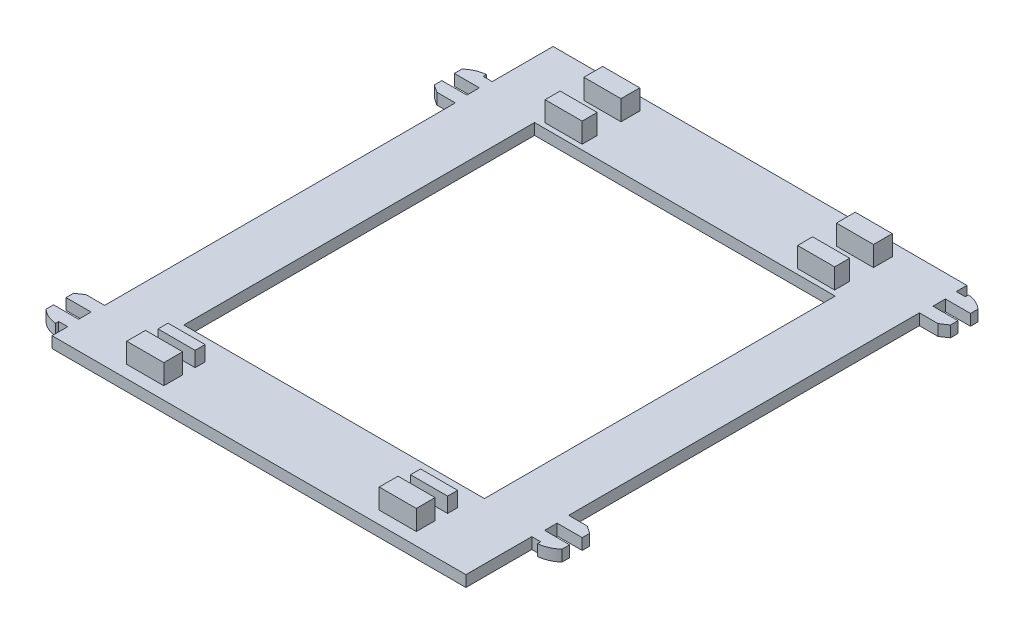
from build123d import *

# Parameters (mm, degrees)
SKETCH1_W           = 0.2
SKETCH1_H           = 2.5
SKETCH1_W_2         = 82.6
SKETCH1_H_2         = 100
BOSS_EXTRUDE1_DEPTH = 2.23
SKETCH2_W           = 7.4
SKETCH2_H           = 3.75
SKETCH2_H_2         = 3
BOSS_EXTRUDE2_DEPTH = 4
SKETCH3_W           = 60
SKETCH3_H           = 70
CUT_EXTRUDE1_DEPTH  = 10
CUT_EXTRUDE2_DEPTH  = 0.5
SKETCH5_W           = 7.4
SKETCH5_H           = 2
BOSS_EXTRUDE3_DEPTH = 3


with BuildPart() as part:
    # Sketch1 → Boss-Extrude1 (new body)
    with BuildSketch(Plane(origin=(0, 0, 0), x_dir=(1, 0, 0), z_dir=(0, 1, 0))):
        with BuildLine():
            Line((43.1, -36.85), (43.1, -37.5))
            ThreePointArc((43.1, -37.5), (44.922195524, -37.020142239), (46.5, -35.99))
            Line((46.5, -35.99), (46.5, -34.49))
            Line((46.5, -34.49), (43.1, -34.49))
            Line((43.1, -34.49), (43.1, -36.85))
        make_face()
        Polygon((41.5, -34.49), (41.3, -34.49), (41.3, -36.85), (43.1, -36.85), (43.1, -34.49), align=None)
        Polygon((45, -29.49), (41.3, -29.49), (41.3, -31.99), (41.5, -31.99), (46.5, -31.99), (46.5, -30.49), align=None)
        with Locations((41.4, -33.24)):
            Rectangle(SKETCH1_W, SKETCH1_H)
        Rectangle(SKETCH1_W_2, SKETCH1_H_2)
        Polygon((46.5, 43.01), (41.5, 43.01), (41.3, 43.01), (41.3, 40.51), (45, 40.51), (46.5, 41.51), align=None)
        with Locations((41.4, 44.26)):
            Rectangle(SKETCH1_W, SKETCH1_H)
        Polygon((41.5, 45.51), (43.1, 45.51), (43.1, 47.87), (41.3, 47.87), (41.3, 45.51), align=None)
        with BuildLine():
            ThreePointArc((43.1, 48.52), (44.922195524, 48.040142239), (46.5, 47.01))
            Line((46.5, 47.01), (46.5, 45.51))
            Line((46.5, 45.51), (43.1, 45.51))
            Line((43.1, 45.51), (43.1, 47.87))
            Line((43.1, 47.87), (43.1, 48.52))
        make_face()
        with BuildLine():
            Line((-43.1, -46.87), (-41.3, -46.87))
            Line((-41.3, -46.87), (-41.3, -44.51))
            Line((-41.3, -44.51), (-41.5, -44.51))
            Line((-41.5, -44.51), (-46.5, -44.51))
            Line((-46.5, -44.51), (-46.5, -46.01))
            ThreePointArc((-46.5, -46.01), (-44.922195524, -47.040142239), (-43.1, -47.52))
            Line((-43.1, -47.52), (-43.1, -46.87))
        make_face()
        Polygon((-41.3, -44.51), (-41.3, -39.51), (-45, -39.51), (-46.5, -40.51), (-46.5, -42.01), (-41.5, -42.01), (-41.5, -44.51), align=None)
        Polygon((-41.3, 30.49), (-41.3, 35.49), (-41.5, 35.49), (-41.5, 32.99), (-46.5, 32.99), (-46.5, 31.49), (-45, 30.49), align=None)
        with BuildLine():
            Line((-41.3, 35.49), (-41.3, 37.85))
            Line((-41.3, 37.85), (-43.1, 37.85))
            Line((-43.1, 37.85), (-43.1, 38.5))
            ThreePointArc((-43.1, 38.5), (-44.922195524, 38.020142239), (-46.5, 36.99))
            Line((-46.5, 36.99), (-46.5, 35.49))
            Line((-46.5, 35.49), (-41.5, 35.49))
            Line((-41.5, 35.49), (-41.3, 35.49))
        make_face()
    extrude(amount=BOSS_EXTRUDE1_DEPTH)

    # Sketch2 → Boss-Extrude2 (add)
    with BuildSketch(Plane(origin=(0, 2.23, 0), x_dir=(1, 0, 0), z_dir=(0, 1, 0))):
        with Locations((-25.2, -45.625)):
            Rectangle(SKETCH2_W, SKETCH2_H)
        with Locations((25.2, -45.625)):
            Rectangle(SKETCH2_W, SKETCH2_H)
        with Locations((25.2, 45.625)):
            Rectangle(SKETCH2_W, SKETCH2_H)
        with Locations((-25.2, 45.625)):
            Rectangle(SKETCH2_W, SKETCH2_H)
        with Locations((-25.2, 37.5)):
            Rectangle(SKETCH2_W, SKETCH2_H_2)
        with Locations((25.2, 37.5)):
            Rectangle(SKETCH2_W, SKETCH2_H_2)
    extrude(amount=BOSS_EXTRUDE2_DEPTH)

    # Sketch3 → Cut-Extrude1 (cut)
    with BuildSketch(Plane(origin=(0, 2.23, 0), x_dir=(1, 0, 0), z_dir=(0, 1, 0))):
        Rectangle(SKETCH3_W, SKETCH3_H)
    extrude(amount=-CUT_EXTRUDE1_DEPTH, mode=Mode.SUBTRACT)

    # Sketch4 → Cut-Extrude2 (cut)
    with BuildSketch(Plane.XZ):
        Polygon((4.640384615, -43.419230769), (4.640384615, -45.291666667), (4.070512821, -45.291666667), (4.070512821, -43.419230769), (2.198076923, -43.419230769), (2.198076923, -42.849358974), (4.070512821, -42.849358974), (4.070512821, -40.976923077), (4.640384615, -40.976923077), (4.640384615, -42.849358974), (6.512820513, -42.849358974), (6.512820513, -43.419230769), align=None)
        Polygon((1.221153846, -45.698717949), (1.221153846, -46.35), (-2.116666667, -46.35), (0.54697516, -40.651282051), (-2.03525641, -40.651282051), (-2.03525641, -40), (1.465384615, -40), (-1.198257212, -45.698717949), align=None)
        with BuildLine():
            add(Edge.make_bspline(
                [(-3.175, -44.482652244), (-3.262918211, -44.565594294), (-3.433284709, -44.726318068), (-3.671176807, -44.969181062), (-3.884395029, -45.204215059), (-4.071386431, -45.432230465), (-4.235563138, -45.650653984), (-4.373446797, -45.862117777), (-4.487450991, -46.065713922), (-4.546079998, -46.202765549), (-4.574238782, -46.268589744)],
                knots=[0, 0, 0, 0, 0.000362575, 0.000702591, 0.001019617, 0.001314251, 0.001586978, 0.001838892, 0.00207117, 0.002285828, 0.002285828, 0.002285828, 0.002285828], degree=3))
            Line((-4.574238782, -46.268589744), (-4.759955929, -46.268589744))
            add(Edge.make_bspline(
                [(-4.759955929, -46.268589744), (-4.792788221, -46.198486652), (-4.860615985, -46.053661673), (-4.986779978, -45.841364869), (-5.132525091, -45.623706079), (-5.300867212, -45.402881295), (-5.491310702, -45.177687257), (-5.702118152, -44.94759275), (-5.93585869, -44.714525691), (-6.101847246, -44.561381426), (-6.187179487, -44.482652244)],
                knots=[0, 0, 0, 0, 0.000232111, 0.000479514, 0.000739881, 0.001017698, 0.001312003, 0.001624408, 0.001953613, 0.002301902, 0.002301902, 0.002301902, 0.002301902], degree=3))
            Line((-6.187179487, -44.482652244), (-6.187179487, -44.151923077))
            add(Edge.make_bspline(
                [(-6.187179487, -44.151923077), (-6.116537815, -44.184471117), (-5.978890638, -44.247891839), (-5.781903944, -44.34935602), (-5.597143614, -44.448436612), (-5.427913951, -44.551377879), (-5.270864773, -44.651733434), (-5.129759329, -44.755968393), (-5.000056754, -44.857829341), (-4.922299946, -44.930706152), (-4.884615385, -44.966025641)],
                knots=[0, 0, 0, 0, 0.000233307, 0.000454604, 0.000664648, 0.000862076, 0.001048719, 0.001223511, 0.001388199, 0.001543075, 0.001543075, 0.001543075, 0.001543075], degree=3))
            Line((-4.884615385, -44.966025641), (-4.884615385, -38.127564103))
            Line((-4.884615385, -38.127564103), (-4.477564103, -38.127564103))
            Line((-4.477564103, -38.127564103), (-4.477564103, -44.966025641))
            add(Edge.make_bspline(
                [(-4.477564103, -44.966025641), (-4.378031962, -44.888388472), (-4.177950241, -44.732320508), (-3.858882125, -44.521130617), (-3.525108924, -44.32477265), (-3.292360048, -44.209864), (-3.175, -44.151923077)],
                knots=[0, 0, 0, 0, 0.000378565, 0.000760999, 0.001146938, 0.001539469, 0.001539469, 0.001539469, 0.001539469], degree=3))
            Line((-3.175, -44.151923077), (-3.175, -44.482652244))
        make_face()
    extrude(amount=-CUT_EXTRUDE2_DEPTH, mode=Mode.SUBTRACT)

    # Sketch5 → Boss-Extrude3 (add)
    with BuildSketch(Plane(origin=(0, 2.23, 0), x_dir=(1, 0, 0), z_dir=(0, 1, 0))):
        with Locations((-25.2, -40.25)):
            Rectangle(SKETCH5_W, SKETCH5_H)
        with Locations((25.2, -40.25)):
            Rectangle(SKETCH5_W, SKETCH5_H)
    extrude(amount=BOSS_EXTRUDE3_DEPTH)


solid = part.part
